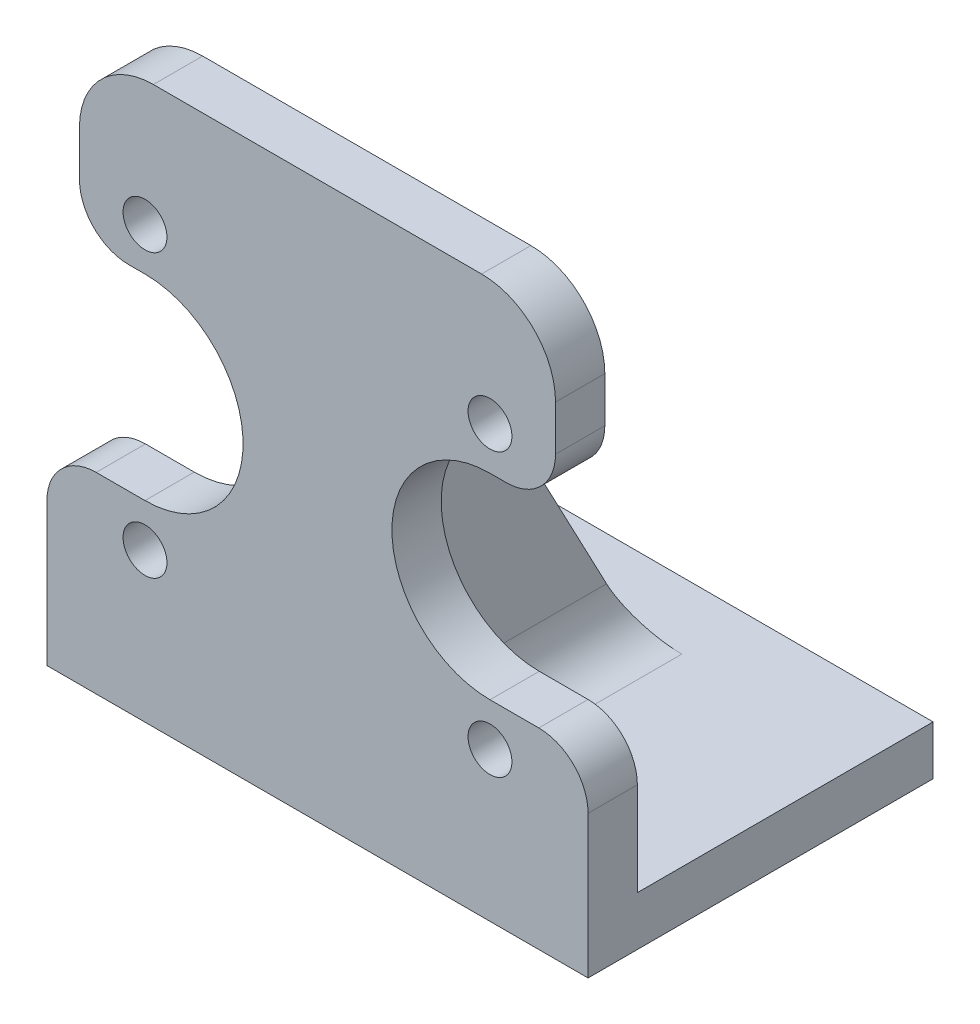
from build123d import *

# Parameters (mm, degrees)
SKETCH1_R           = 4.45
BOSS_EXTRUDE1_DEPTH = 10
BOSS_EXTRUDE2_START = 10.1
SKETCH2_W           = 60
SKETCH2_H           = 10
BOSS_EXTRUDE2_DEPTH = 109.8
BOSS_EXTRUDE3_DEPTH = 7.5
FILLET1_R           = 10
FILLET2_R           = 10


with BuildPart() as part:
    # Sketch1 → Boss-Extrude1 (new body)
    with BuildSketch(Plane.XY):
        with BuildLine():
            Line((62.029952175, 0), (119.9, 0))
            Line((119.9, 0), (119.9, 28.94))
            ThreePointArc((119.9, 28.94), (116.971067812, 36.011067812), (109.9, 38.94))
            Line((109.9, 38.94), (100, 38.94))
            ThreePointArc((100, 38.94), (80.1, 58.84), (100, 78.74))
            Line((100, 78.74), (103.295753204, 78.74))
            ThreePointArc((103.295753204, 78.74), (110.366821016, 81.668932188), (113.295753204, 88.74))
            Line((113.295753204, 88.74), (113.295753204, 97.89474782))
            ThreePointArc((113.295753204, 97.89474782), (108.902354922, 108.501349538), (98.295753204, 112.89474782))
            Line((98.295753204, 112.89474782), (31.704246796, 112.89474782))
            ThreePointArc((31.704246796, 112.89474782), (21.097645078, 108.501349538), (16.704246796, 97.89474782))
            Line((16.704246796, 97.89474782), (16.704246796, 88.74))
            ThreePointArc((16.704246796, 88.74), (19.633178984, 81.668932188), (26.704246796, 78.74))
            Line((26.704246796, 78.74), (30, 78.74))
            ThreePointArc((30, 78.74), (49.9, 58.84), (30, 38.94))
            Line((30, 38.94), (20.1, 38.94))
            ThreePointArc((20.1, 38.94), (13.028932188, 36.011067812), (10.1, 28.94))
            Line((10.1, 28.94), (10.1, 0))
            Line((10.1, 0), (62.029952175, 0))
        make_face()
        with Locations((30, 30.24)):
            Circle(SKETCH1_R, mode=Mode.SUBTRACT)
        with Locations((30, 87.44)):
            Circle(SKETCH1_R, mode=Mode.SUBTRACT)
        with Locations((100, 30.24)):
            Circle(SKETCH1_R, mode=Mode.SUBTRACT)
        with Locations((100, 87.44)):
            Circle(SKETCH1_R, mode=Mode.SUBTRACT)
    extrude(amount=-BOSS_EXTRUDE1_DEPTH)

    # Sketch2 → Boss-Extrude2 (add)
    with BuildSketch(Plane(origin=(0, 0, 0), x_dir=(0, 0, -1), z_dir=(1, 0, 0)).offset(BOSS_EXTRUDE2_START)):
        with Locations((40, 5)):
            Rectangle(SKETCH2_W, SKETCH2_H)
    extrude(amount=BOSS_EXTRUDE2_DEPTH)

    # Sketch3 → Boss-Extrude3 (add, symmetric)
    with BuildSketch(Plane.ZY.offset(-65)):
        Polygon((-10, 97.89474782), (-10, 10), (-56.427715737, 10), align=None)
    extrude(amount=BOSS_EXTRUDE3_DEPTH, both=True)

    # Fillet1
    fillet1_edges = [part.edges().sort_by_distance(p)[0] for p in [
        (72.5, 10, -33.213857868),
    ]]
    fillet(fillet1_edges, radius=FILLET1_R)

    # Fillet2
    fillet2_edges = [part.edges().sort_by_distance(p)[0] for p in [
        (57.5, 10, -33.213857868),
    ]]
    fillet(fillet2_edges, radius=FILLET2_R)


solid = part.part
